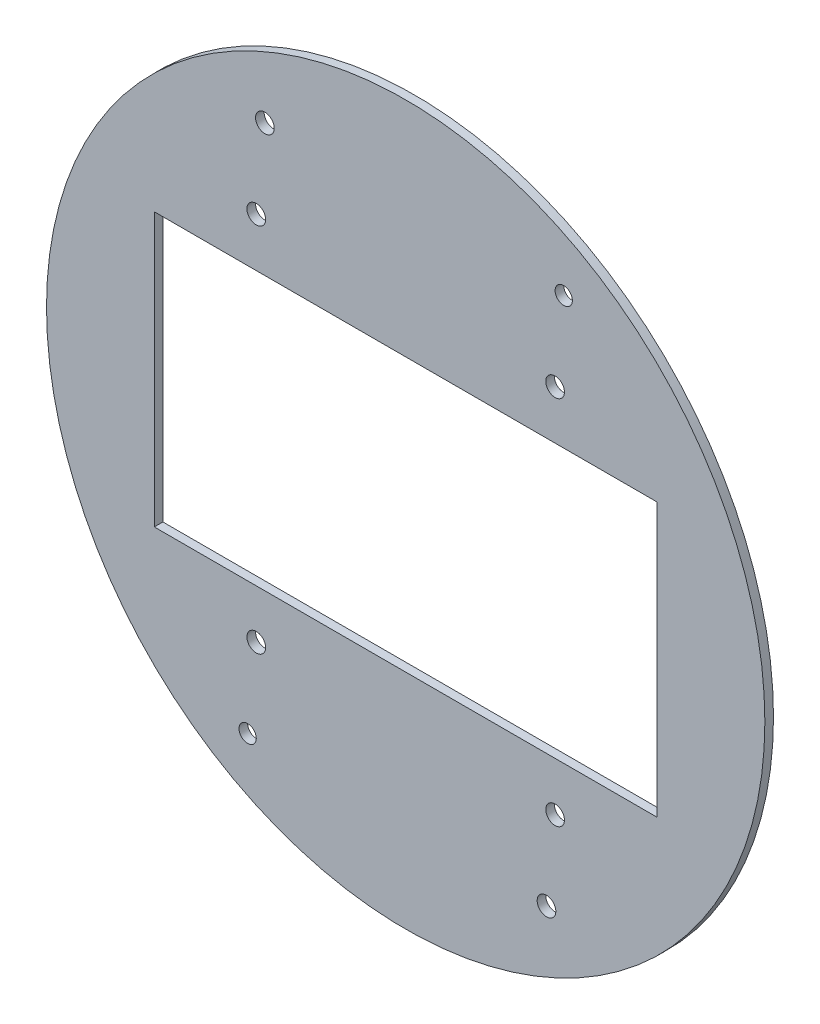
from build123d import *

# Parameters (mm, degrees)
SKETCH1_R           = 125
SKETCH1_W           = 175
SKETCH1_H           = 95
BOSS_EXTRUDE1_DEPTH = 3
SKETCH2_R           = 3.25
SKETCH2_R_2         = 3
CUT_EXTRUDE1_DEPTH  = 4


with BuildPart() as part:
    # Sketch1 → Boss-Extrude1 (new body)
    with BuildSketch(Plane.XY):
        Circle(SKETCH1_R)
        Rectangle(SKETCH1_W, SKETCH1_H, mode=Mode.SUBTRACT)
    extrude(amount=BOSS_EXTRUDE1_DEPTH)

    # Sketch2 → Cut-Extrude1 (cut, through all)
    with BuildSketch(Plane.XY.offset(3)):
        with Locations((-52, -64.5)):
            Circle(SKETCH2_R)
        with Locations((-55, -93.5)):
            Circle(SKETCH2_R_2)
        with Locations((52, 64.5)):
            Circle(SKETCH2_R)
        with Locations((55, 93.5)):
            Circle(SKETCH2_R_2)
        with Locations((52, -64.5)):
            Circle(SKETCH2_R)
        with Locations((-52, 64.5)):
            Circle(SKETCH2_R)
        with Locations((49, -93.5)):
            Circle(SKETCH2_R)
        with Locations((-49, 93.5)):
            Circle(SKETCH2_R)
    extrude(amount=-CUT_EXTRUDE1_DEPTH, mode=Mode.SUBTRACT)


solid = part.part
